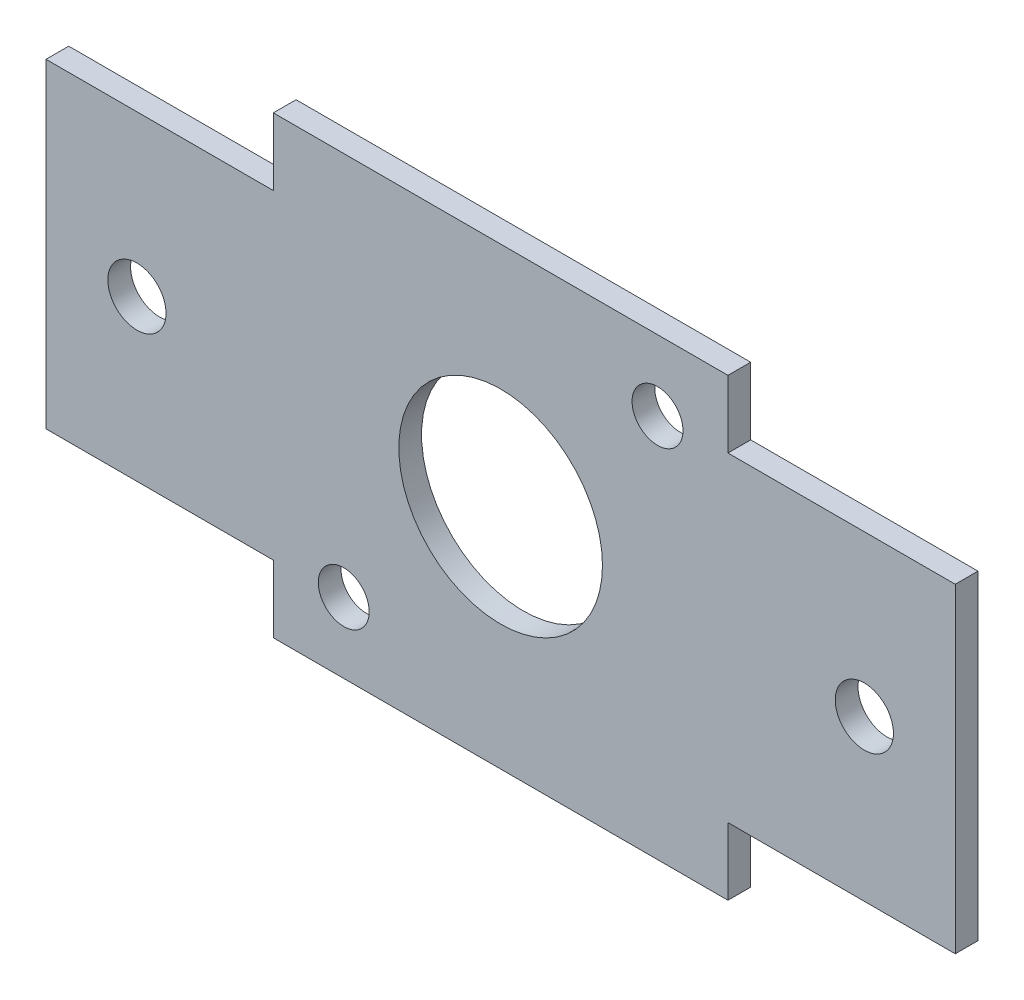
from build123d import *

# Parameters (mm, degrees)
SKETCH1_W           = 15.875
SKETCH1_H           = 22.352
SKETCH1_R           = 2.032
SKETCH1_W_2         = 31.75
SKETCH1_H_2         = 31.75
SKETCH1_R_2         = 7.112
SKETCH1_R_3         = 1.778
BOSS_EXTRUDE1_DEPTH = 1.5875


with BuildPart() as part:
    # Sketch1 → Boss-Extrude1 (new body)
    with BuildSketch(Plane.XY):
        with Locations((-23.8125, 0)):
            Rectangle(SKETCH1_W, SKETCH1_H)
        with Locations((-25.4, 0)):
            Circle(SKETCH1_R, mode=Mode.SUBTRACT)
        Rectangle(SKETCH1_W_2, SKETCH1_H_2)
        Circle(SKETCH1_R_2, mode=Mode.SUBTRACT)
        with Locations((-10.955912468, -10.955912468)):
            Circle(SKETCH1_R_3, mode=Mode.SUBTRACT)
        with Locations((10.955912468, 10.955912468)):
            Circle(SKETCH1_R_3, mode=Mode.SUBTRACT)
        with Locations((23.8125, 0)):
            Rectangle(SKETCH1_W, SKETCH1_H)
        with Locations((25.4, 0)):
            Circle(SKETCH1_R, mode=Mode.SUBTRACT)
    extrude(amount=BOSS_EXTRUDE1_DEPTH)


solid = part.part
